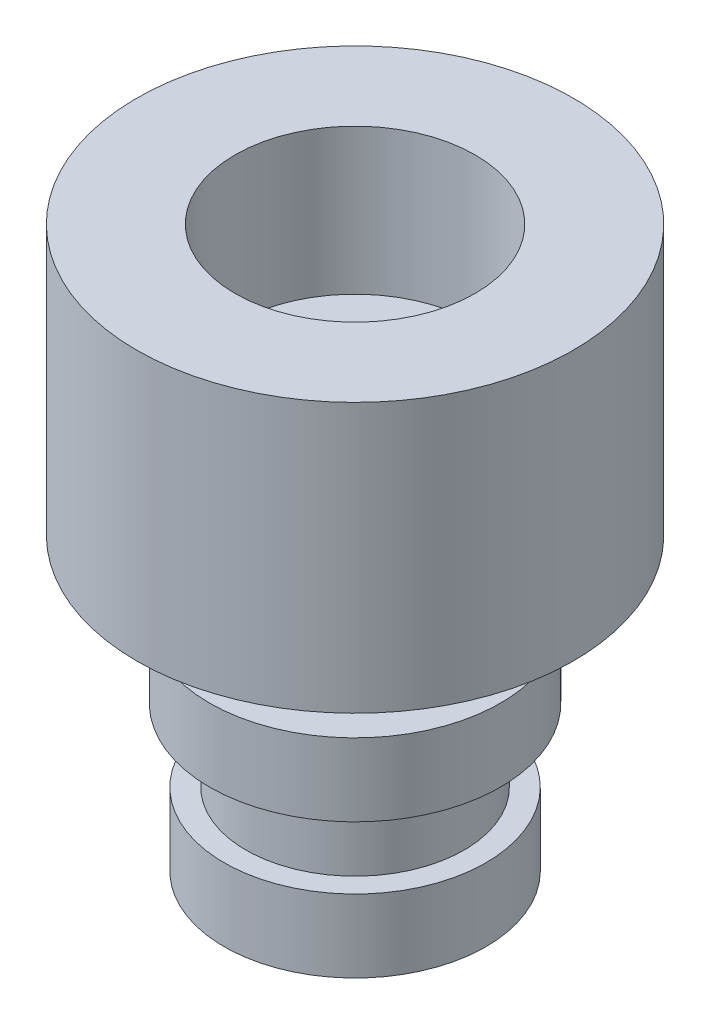
from build123d import *

# Parameters (mm, degrees)
SKETCH1_R           = 3
BOSS_EXTRUDE1_DEPTH = 3.7
SKETCH1_3_R         = 1.6
BOSS_EXTRUDE2_DEPTH = 1
SKETCH5_R           = 1.5
BOSS_EXTRUDE3_DEPTH = 1
SKETCH6_R           = 2
BOSS_EXTRUDE4_DEPTH = 1
SKETCH8_R           = 1.5
BOSS_EXTRUDE5_DEPTH = 2
SKETCH10_R          = 1.8
BOSS_EXTRUDE6_DEPTH = 1
SKETCH12_R          = 1.65
CUT_EXTRUDE1_DEPTH  = 2


with BuildPart() as part:
    # Sketch1 → Boss-Extrude1 (new body)
    with BuildSketch(Plane(origin=(0, 0, 0), x_dir=(1, 0, 0), z_dir=(0, 1, 0))):
        with Locations((-0.522013312, 0.511138034)):
            Circle(SKETCH1_R)
    extrude(amount=BOSS_EXTRUDE1_DEPTH)

    # Sketch1_3 → Boss-Extrude2 (add)
    with BuildSketch(Plane(origin=(0, 0, 0), x_dir=(1, 0, 0), z_dir=(0, 1, 0))):
        with Locations((-0.522013312, 0.511138034)):
            Circle(SKETCH1_3_R)
    extrude(amount=BOSS_EXTRUDE2_DEPTH)

    # Sketch5 → Boss-Extrude3 (add)
    with BuildSketch(Plane.XZ):
        with Locations((-0.522013312, -0.511138034)):
            Circle(SKETCH5_R)
    extrude(amount=BOSS_EXTRUDE3_DEPTH)

    # Sketch6 → Boss-Extrude4 (add)
    with BuildSketch(Plane.XZ.offset(1)):
        with Locations((-0.522013312, -0.511138034)):
            Circle(SKETCH6_R)
    extrude(amount=BOSS_EXTRUDE4_DEPTH)

    # Sketch8 → Boss-Extrude5 (add)
    with BuildSketch(Plane(origin=(0, -2, 0), x_dir=(-1, 0, 0), z_dir=(0, -1, 0))):
        with Locations((0.522013312, 0.511138034)):
            Circle(SKETCH8_R)
    extrude(amount=BOSS_EXTRUDE5_DEPTH)

    # Sketch10 → Boss-Extrude6 (add)
    with BuildSketch(Plane.XZ.offset(4)):
        with Locations((-0.522013312, -0.511138034)):
            Circle(SKETCH10_R)
    extrude(amount=-BOSS_EXTRUDE6_DEPTH)

    # Sketch12 → Cut-Extrude1 (cut)
    with BuildSketch(Plane(origin=(0, 3.7, 0), x_dir=(1, 0, 0), z_dir=(0, 1, 0))):
        with Locations((-0.522013312, 0.511138034)):
            Circle(SKETCH12_R)
    extrude(amount=-CUT_EXTRUDE1_DEPTH, mode=Mode.SUBTRACT)


solid = part.part
